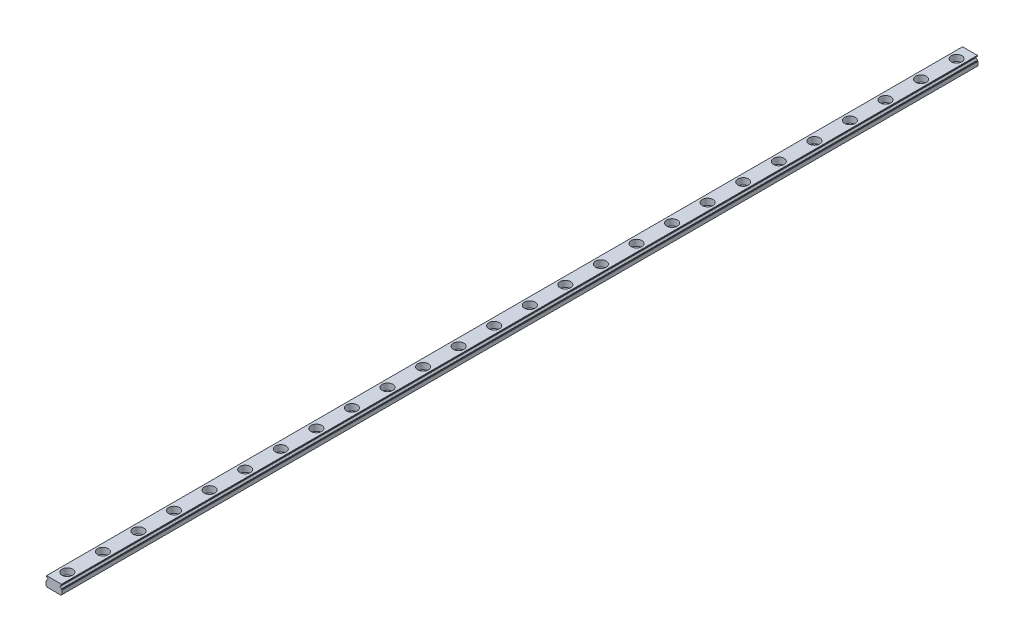
from build123d import *

# Parameters (mm, degrees)
SKETCH1_W       = 9
SKETCH1_H       = 5.5
EXTRUDE1_DEPTH  = 257.5
SKETCH2_R       = 3
SKETCH2_R_2     = 1.75
EXTRUDE2_DEPTH  = 3.5
SKETCH2_3_R     = 1.75
EXTRUDE5_DEPTH  = 258.598039589
LPATTERN1_COUNT = 26
LPATTERN1_PITCH = 20
EXTRUDE6_DEPTH  = 516.049026793
CHAMFER1_SIZE   = 0.55


with BuildPart() as part:
    # Sketch1 → Extrude1 (new, symmetric)
    with BuildSketch(Plane.XY):
        with Locations((0, 2.75)):
            Rectangle(SKETCH1_W, SKETCH1_H)
    extrude(amount=EXTRUDE1_DEPTH, both=True)

    # Sketch2 → Extrude2 (cut)
    with BuildSketch(Plane(origin=(0, 5.5, 0), x_dir=(1, 0, 0), z_dir=(0, 1, 0))):
        with Locations((0, -250)):
            Circle(SKETCH2_R)
        with Locations((0, -250)):
            Circle(SKETCH2_R_2, mode=Mode.SUBTRACT)
    extrude2 = extrude(amount=-EXTRUDE2_DEPTH, mode=Mode.SUBTRACT)

    # Sketch2_3 → Extrude5 (cut, through all)
    with BuildSketch(Plane(origin=(0, 5.5, 0), x_dir=(1, 0, 0), z_dir=(0, 1, 0))):
        with Locations((0, -250)):
            Circle(SKETCH2_3_R)
    extrude5 = extrude(amount=-EXTRUDE5_DEPTH, mode=Mode.SUBTRACT)

    # LPattern1: Extrude2, Extrude5 ×26
    with Locations(*[(0, 0, -i * LPATTERN1_PITCH) for i in range(1, LPATTERN1_COUNT)]):
        add(extrude2, mode=Mode.SUBTRACT)
        add(extrude5, mode=Mode.SUBTRACT)

    # Sketch3 → Extrude6 (cut, through all)
    with BuildSketch(Plane.XY.offset(257.5)):
        Polygon((-4.2, 5.041666667), (-3.433333333, 4.275), (-3.283333333, 4.275), (-3.283333333, 3.975), (-3.433333333, 3.975), (-4.2, 3.208333333), (-4.2, 2.75), (-4.5, 2.75), (-4.5, 5.5), (-4.2, 5.5), align=None)
        Polygon((3.283333333, 3.975), (3.433333333, 3.975), (4.2, 3.208333333), (4.2, 2.75), (4.5, 2.75), (4.5, 5.5), (4.2, 5.5), (4.2, 5.041666667), (3.433333333, 4.275), (3.283333333, 4.275), align=None)
    extrude(amount=-EXTRUDE6_DEPTH, mode=Mode.SUBTRACT)

    # Chamfer1
    chamfer1_edges = [part.edges().sort_by_distance(p)[0] for p in [
        (-4.5, 0, 0),
        (4.5, 0, 0),
    ]]
    chamfer(chamfer1_edges, length=CHAMFER1_SIZE)


solid = part.part
